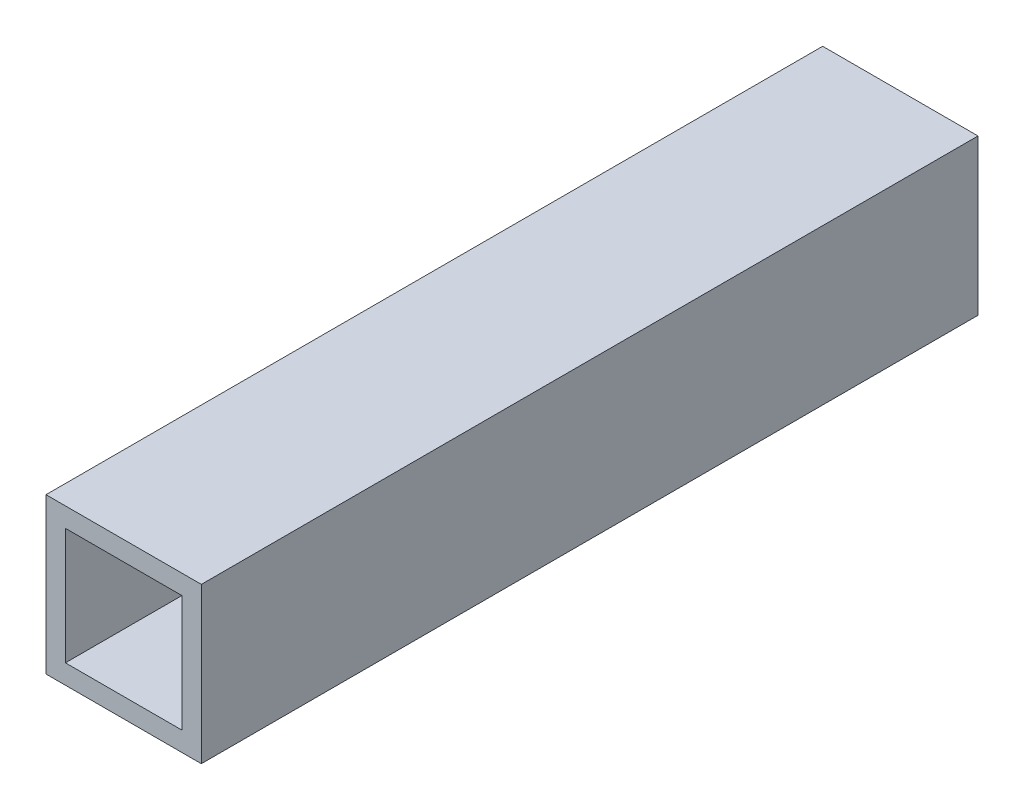
from build123d import *

# Parameters (mm, degrees)
SKETCH1_W           = 25.4
SKETCH1_H           = 25.4
BOSS_EXTRUDE1_DEPTH = 63.5
SHELL1_T            = -3.175


with BuildPart() as part:
    # Sketch1 → Boss-Extrude1 (new body, symmetric)
    with BuildSketch(Plane.XY):
        Rectangle(SKETCH1_W, SKETCH1_H)
    extrude(amount=BOSS_EXTRUDE1_DEPTH, both=True)

    # Shell1
    shell1_openings = [part.faces().sort_by_distance(p)[0] for p in [
        (0, 0, 63.5),
        (0, 0, -63.5),
    ]]
    offset(amount=SHELL1_T, openings=shell1_openings, kind=Kind.INTERSECTION)


solid = part.part
